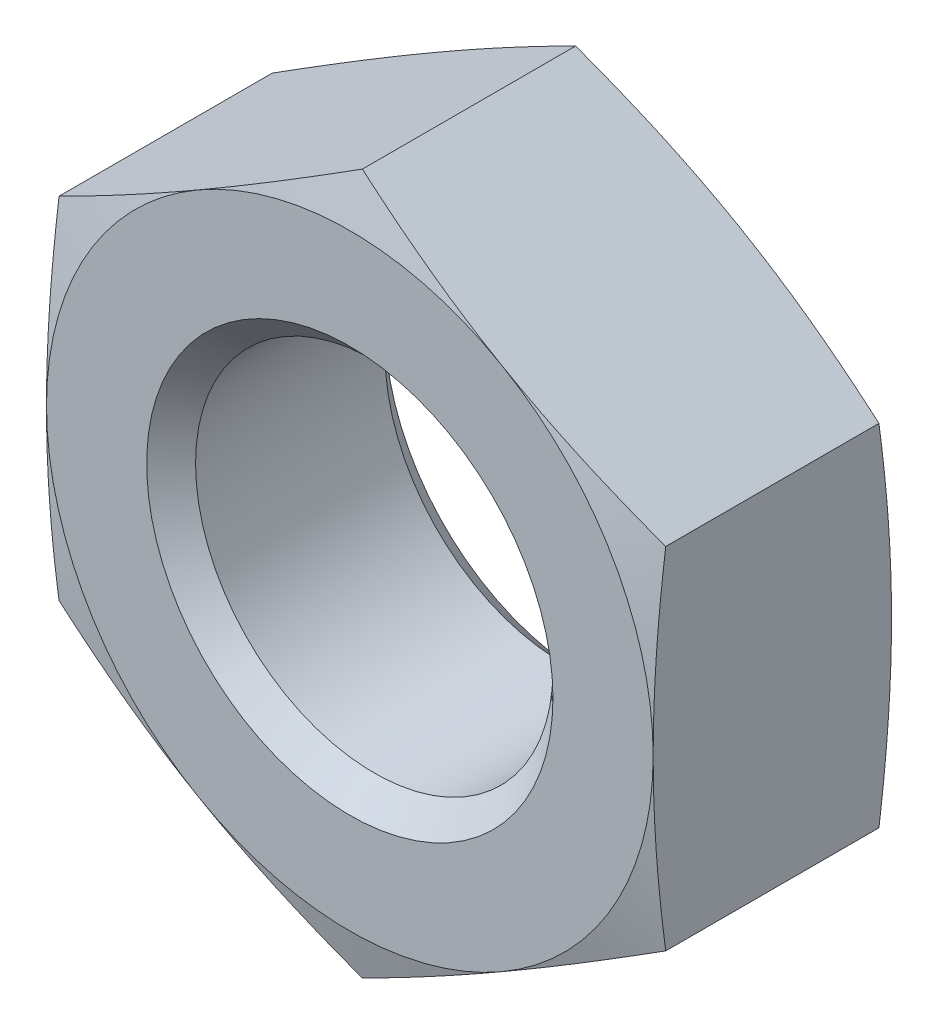
from build123d import *

# Parameters (mm, degrees)
SKETCH2_W          = 28.448
SKETCH2_H          = 28.448
CUT_EXTRUDE1_DEPTH = 5.588


with BuildPart() as part:
    # Sketch1 → Revolve1 (revolve)
    with BuildSketch(Plane(origin=(0, 0, 0), x_dir=(0, 0, -1), z_dir=(1, 0, 0))):
        Polygon((0, 0), (0, 7.112), (0.381130931, 8.5344), (5.206869069, 8.5344), (5.588, 7.112), (5.588, 0), align=None)
    revolve(axis=Axis((0, 0, -5.588), (0, 0, 1)))

    # Sketch2 → Cut-Extrude1 (cut)
    with BuildSketch(Plane.XY):
        Rectangle(SKETCH2_W, SKETCH2_H)
        Polygon((-7.112, -4.106115114), (0, -8.212230229), (7.112, -4.106115114), (7.112, 4.106115114), (0, 8.212230229), (-7.112, 4.106115114), align=None, mode=Mode.SUBTRACT)
    extrude(amount=-CUT_EXTRUDE1_DEPTH, mode=Mode.SUBTRACT)

    # Sketch3 → Cut-Revolve1 (revolve, cut)
    with BuildSketch(Plane(origin=(0, 0, 0), x_dir=(0, 0, -1), z_dir=(1, 0, 0))):
        Polygon((0, 0), (0, 4.7625), (0.57277, 4.18973), (5.01523, 4.18973), (5.588, 4.7625), (5.588, 0), align=None)
    revolve(axis=Axis((0, 0, -5.588), (0, 0, 1)), mode=Mode.SUBTRACT)


solid = part.part
